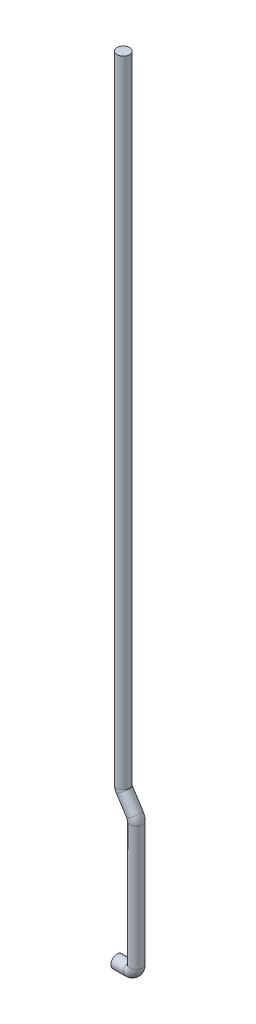
from build123d import *

# Parameters (mm, degrees)
SKETCH17_R = 4


with BuildPart() as part:
    # Sweep22: sweep along a path in Sketch3
    with BuildLine(Plane.XY) as sweep22_path:
        Line((0, 0), (8, 0))
        ThreePointArc((8, 0), (11.076281797, 1.274237642), (12.350519439, 4.350519439))
        Line((12.350519439, 4.350519439), (12.350519439, 84.031538443))
        ThreePointArc((12.350519439, 84.031538443), (12.105003941, 85.738751653), (11.388356434, 87.307595544))
        Line((11.388356434, 87.307595544), (4.687742411, 97.731045235))
        ThreePointArc((4.687742411, 97.731045235), (4.173118642, 98.85763027), (3.996814239, 100.083578158))
        Line((3.996814239, 100.083578158), (3.996814239, 508.128789654))
    # Sketch17 → Sweep22 (sweep)
    with BuildSketch(Plane(origin=(0, 0, 0), x_dir=(0, 0, -1), z_dir=(1, 0, 0))):
        Circle(SKETCH17_R)
    sweep(path=sweep22_path.line)


solid = part.part
